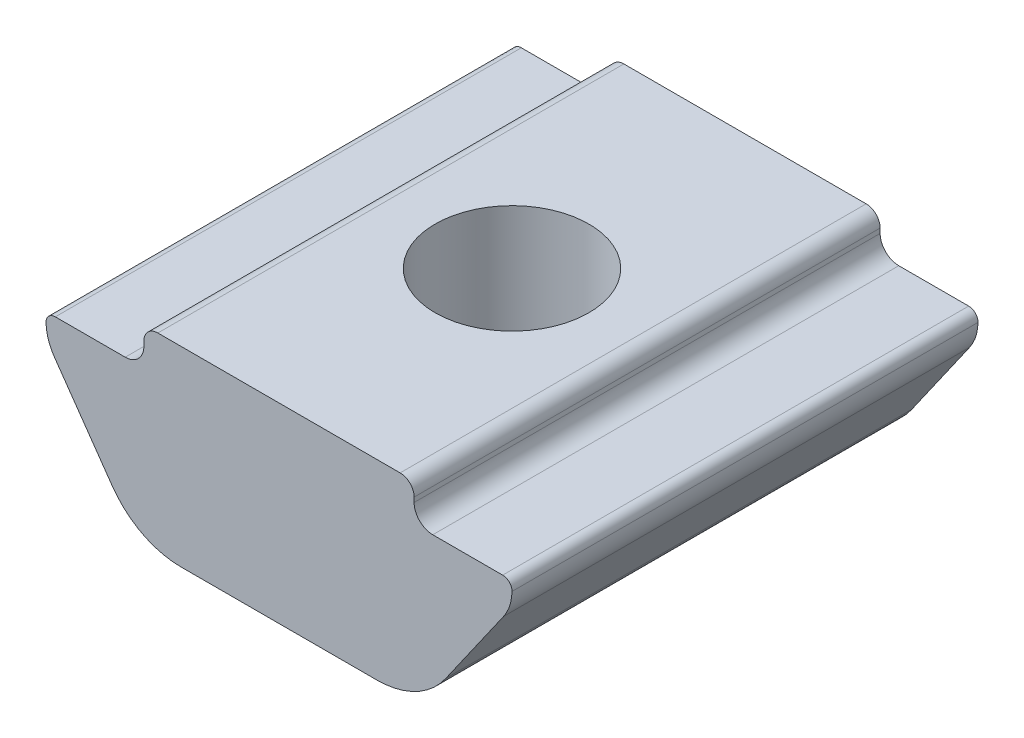
from build123d import *

# Parameters (mm, degrees)
EXTRUDE_1_DEPTH = 5
M4X0_7_1_D      = 3.3


with BuildPart() as part:
    # ｽｹｯﾁ2 → 押し出し1 (new body, symmetric)
    with BuildSketch(Plane.XY):
        with BuildLine():
            Line((2.89985476, -0.30000001), (2.89985476, -0.39999919))
            ThreePointArc((2.89985476, -0.39999919), (3.017012051, -0.68284191), (3.29985477, -0.7999992))
            Line((3.29985477, -0.7999992), (4.799856544, -0.7999992))
            ThreePointArc((4.799856544, -0.7999992), (4.942617804, -0.859930564), (4.999820293, -1.003806973))
            ThreePointArc((4.999820293, -1.003806973), (4.950834117, -1.294473494), (4.819233264, -1.558230745))
            Line((4.819233264, -1.558230745), (3.577430107, -3.332233905))
            ThreePointArc((3.577430107, -3.332233905), (2.934071419, -3.896562924), (2.102813019, -4.100001158))
            Line((2.102813019, -4.100001158), (-2.102813019, -4.100001158))
            ThreePointArc((-2.102813019, -4.100001158), (-2.934071419, -3.896562924), (-3.577430107, -3.332233905))
            Line((-3.577430107, -3.332233905), (-4.819233264, -1.558230745))
            ThreePointArc((-4.819233264, -1.558230745), (-4.950834117, -1.294473494), (-4.999820293, -1.003806973))
            ThreePointArc((-4.999820293, -1.003806973), (-4.942617804, -0.859930564), (-4.799856544, -0.7999992))
            Line((-4.799856544, -0.7999992), (-3.29985477, -0.7999992))
            ThreePointArc((-3.29985477, -0.7999992), (-3.017012051, -0.68284191), (-2.89985476, -0.39999919))
            Line((-2.89985476, -0.39999919), (-2.89985476, -0.30000001))
            ThreePointArc((-2.89985476, -0.30000001), (-2.811986792, -0.087867969), (-2.59985475, 0))
            Line((-2.59985475, 0), (2.59985475, 0))
            ThreePointArc((2.59985475, 0), (2.811986792, -0.087867969), (2.89985476, -0.30000001))
        make_face()
    extrude(amount=EXTRUDE_1_DEPTH, both=True)

    # M4x0.7 ねじ穴1 (through all)
    with Locations(Plane(origin=(0, 0, 0), x_dir=(-1, 0, 0), z_dir=(0, 1, 0))):
        with Locations((0, 0)):
            Hole(M4X0_7_1_D / 2)


solid = part.part
